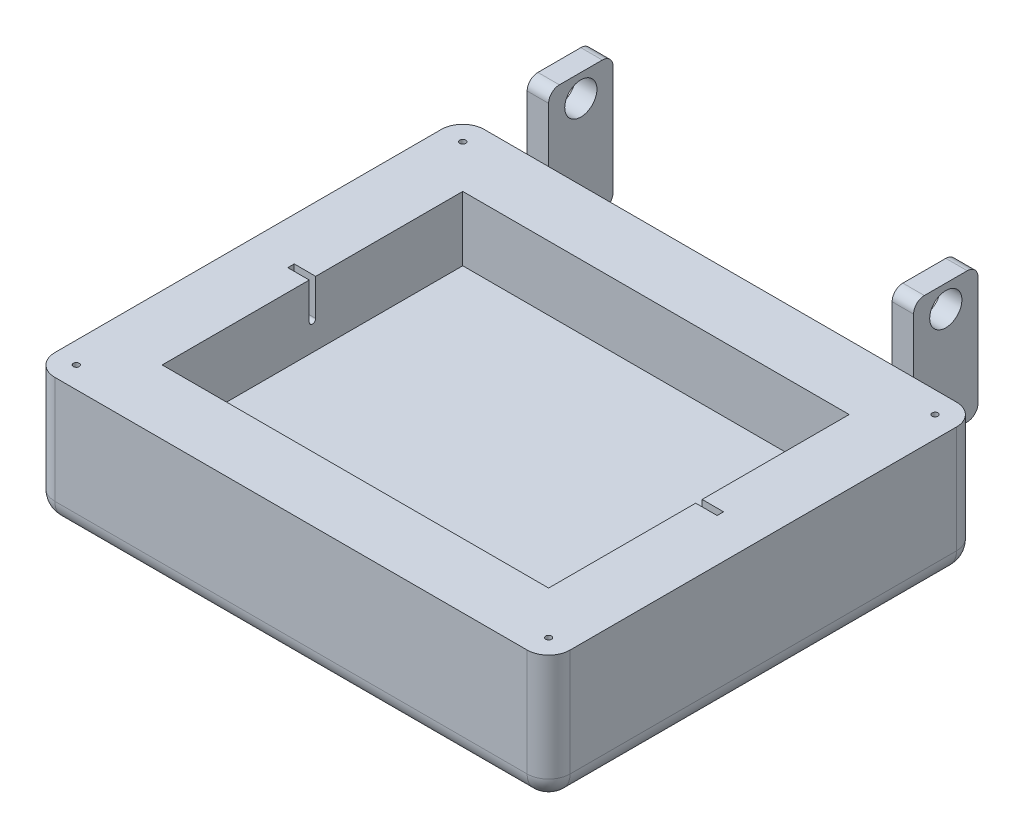
from build123d import *

# Parameters (mm, degrees)
SKETCH4_W                 = 304.8
SKETCH4_H                 = 254
BOSS_EXTRUDE1_DEPTH       = 76.2
SKETCH5_W                 = 228.6
SKETCH5_H                 = 177.8
CUT_EXTRUDE1_DEPTH        = 38.1
FILLET1_R                 = 12.7
SKETCH11_W                = 12.7
SKETCH11_H                = 38.1
BOSS_EXTRUDE2_DEPTH       = 38.735
SKETCH12_R                = 9.525
CUT_EXTRUDE4_DEPTH        = 267.7
FILLET3_R                 = 6.35
SKETCH13_W                = 254
SKETCH13_H                = 3.81
CUT_EXTRUDE5_DEPTH        = 23.495
BOSS_EXTRUDE3_DEPTH       = 12.7
FILLET5_R                 = 6.35
F_8_32_TAPPED_HOLE1_D     = 3.4544
F_8_32_TAPPED_HOLE1_DEPTH = 9.652
F_8_32_TAPPED_HOLE1_TIP   = 1.037806461


with BuildPart() as part:
    # Sketch4 → Boss-Extrude1 (new body)
    with BuildSketch(Plane(origin=(0, 0, 0), x_dir=(1, 0, 0), z_dir=(0, 1, 0))):
        Rectangle(SKETCH4_W, SKETCH4_H)
    extrude(amount=BOSS_EXTRUDE1_DEPTH)

    # Sketch5 → Cut-Extrude1 (cut)
    with BuildSketch(Plane(origin=(0, 76.2, 0), x_dir=(1, 0, 0), z_dir=(0, 1, 0))):
        Rectangle(SKETCH5_W, SKETCH5_H)
    extrude(amount=-CUT_EXTRUDE1_DEPTH, mode=Mode.SUBTRACT)

    # Fillet1
    fillet1_edges = [part.edges().sort_by_distance(p)[0] for p in [
        (0, 0, 127),
        (-152.4, 0, 0),
        (0, 0, -127),
        (152.4, 0, 0),
        (152.4, 38.1, 127),
        (-152.4, 38.1, 127),
        (-152.4, 38.1, -127),
        (152.4, 38.1, -127),
    ]]
    fillet(fillet1_edges, radius=FILLET1_R)

    # Sketch11 → Boss-Extrude2 (add, symmetric)
    with BuildSketch(Plane(origin=(0, 76.2, 0), x_dir=(1, 0, 0), z_dir=(0, 1, 0))):
        with Locations((-107.95, 146.05)):
            Rectangle(SKETCH11_W, SKETCH11_H)
        with Locations((107.95, 146.05)):
            Rectangle(SKETCH11_W, SKETCH11_H)
    extrude(amount=BOSS_EXTRUDE2_DEPTH, both=True)

    # Sketch12 → Cut-Extrude4 (cut, through all)
    with BuildSketch(Plane.ZY.offset(114.3)):
        with Locations((-146.05, 101.6)):
            Circle(SKETCH12_R)
    extrude(amount=-CUT_EXTRUDE4_DEPTH, mode=Mode.SUBTRACT)

    # Fillet3
    fillet3_edges = [part.edges().sort_by_distance(p)[0] for p in [
        (-107.95, 114.935, -127),
        (107.95, 114.935, -127),
    ]]
    fillet(fillet3_edges, radius=FILLET3_R)

    # Sketch13 → Cut-Extrude5 (cut)
    with BuildSketch(Plane(origin=(0, 76.2, 0), x_dir=(1, 0, 0), z_dir=(0, 1, 0))):
        Rectangle(SKETCH13_W, SKETCH13_H)
    extrude(amount=-CUT_EXTRUDE5_DEPTH, mode=Mode.SUBTRACT)

    # Sketch18 → Boss-Extrude3 (add)
    with BuildSketch(Plane(origin=(-127, 0, 0), x_dir=(0, 0, -1), z_dir=(1, 0, 0))):
        with BuildLine():
            Line((-1.905, 52.705), (1.3e-08, 52.705))
            ThreePointArc((1.3e-08, 52.705), (-1.347038413, 53.262961577), (-1.905, 54.61))
            Line((-1.905, 54.61), (-1.905, 52.705))
        make_face()
        with BuildLine():
            Line((1.905, 52.705), (1.905, 54.61))
            ThreePointArc((1.905, 54.61), (1.347038423, 53.262961587), (1.3e-08, 52.705))
            Line((1.3e-08, 52.705), (1.905, 52.705))
        make_face()
    boss_extrude3 = extrude(amount=BOSS_EXTRUDE3_DEPTH)

    # Mirror1: Boss-Extrude3 across plane
    add(boss_extrude3.mirror(Plane(origin=(0, 0, 0), x_dir=(0, 0, 1), z_dir=(1, 0, 0))))

    # Fillet5
    fillet5_edges = [part.edges().sort_by_distance(p)[0] for p in [
        (-107.95, 37.465, -165.1),
        (-107.95, 114.935, -165.1),
        (107.95, 37.465, -165.1),
        (107.95, 114.935, -165.1),
    ]]
    fillet(fillet5_edges, radius=FILLET5_R)

    # #8-32 Tapped Hole1
    with Locations(Plane(origin=(0, 76.2, 0), x_dir=(1, 0, 0), z_dir=(0, 1, 0))):
        with Locations((-139.7, -114.3), (-139.7, 114.3), (139.7, 114.3), (139.7, -114.3)):
            Hole(F_8_32_TAPPED_HOLE1_D / 2, depth=F_8_32_TAPPED_HOLE1_DEPTH)
            with Locations((0, 0, -(F_8_32_TAPPED_HOLE1_DEPTH + F_8_32_TAPPED_HOLE1_TIP / 2))):  # 118° drill point
                Cone(0, F_8_32_TAPPED_HOLE1_D / 2, F_8_32_TAPPED_HOLE1_TIP, mode=Mode.SUBTRACT)


solid = part.part
